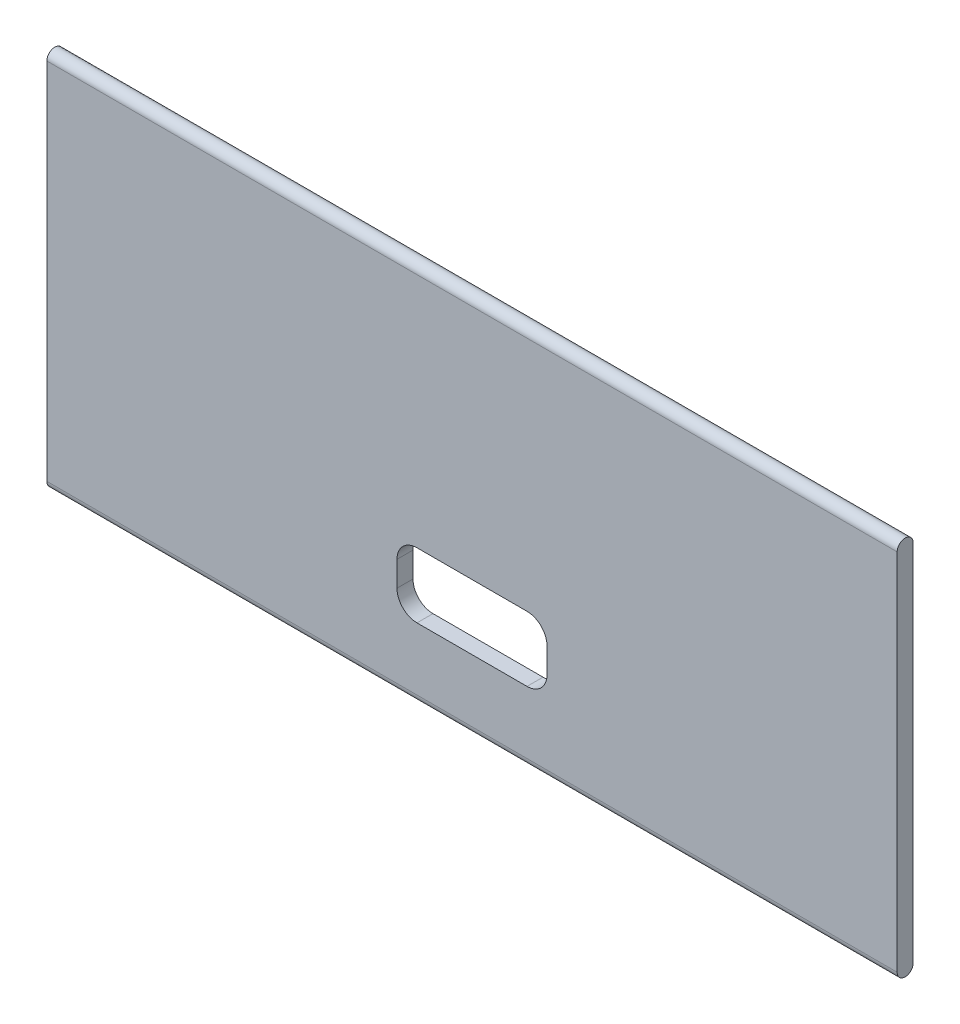
from build123d import *

# Parameters (mm, degrees)
BOSS_EXTRUDE1_DEPTH = 85
CUT_EXTRUDE1_REACH  = 3.6


with BuildPart() as part:
    # Sketch1 → Boss-Extrude1 (new body)
    with BuildSketch(Plane(origin=(0, 0, 0), x_dir=(0, 0, -1), z_dir=(1, 0, 0))):
        with BuildLine():
            Line((0.800009932, 17.208466352), (0.800009932, -18.202808875))
            ThreePointArc((0.800009932, -18.202808875), (-0.005627681, -18.997171261), (-0.799990068, -18.191533648))
            Line((-0.799990068, -18.191533648), (-0.799990068, 18.197191125))
            ThreePointArc((-0.799990068, 18.197191125), (9.932e-06, 18.997191125), (0.800009932, 18.197191125))
            Line((0.800009932, 18.197191125), (0.800009932, 17.208466352))
        make_face()
    extrude(amount=BOSS_EXTRUDE1_DEPTH)

    # Sketch2 → Cut-Extrude1 (cut, up to next)
    with BuildSketch(Plane.XY.offset(0.799990068), mode=Mode.PRIVATE) as cut_extrude1_sk1:
        with BuildLine():
            Line((37, -5.447171261), (48, -5.447171261))
            ThreePointArc((48, -5.447171261), (49.414213562, -6.032957699), (50, -7.447171261))
            Line((50, -7.447171261), (50, -9.947171261))
            ThreePointArc((50, -9.947171261), (49.414213562, -11.361384824), (48, -11.947171261))
            Line((48, -11.947171261), (37, -11.947171261))
            ThreePointArc((37, -11.947171261), (35.585786438, -11.361384824), (35, -9.947171261))
            Line((35, -9.947171261), (35, -7.447171261))
            ThreePointArc((35, -7.447171261), (35.585786438, -6.032957699), (37, -5.447171261))
        make_face()
    cut_extrude1_tool1 = extrude(cut_extrude1_sk1.sketch, amount=-CUT_EXTRUDE1_REACH, mode=Mode.PRIVATE) & part.part
    add(cut_extrude1_tool1.solids().sort_by_distance((42.5, -8.697171, 0.79999))[0], mode=Mode.SUBTRACT)


solid = part.part
